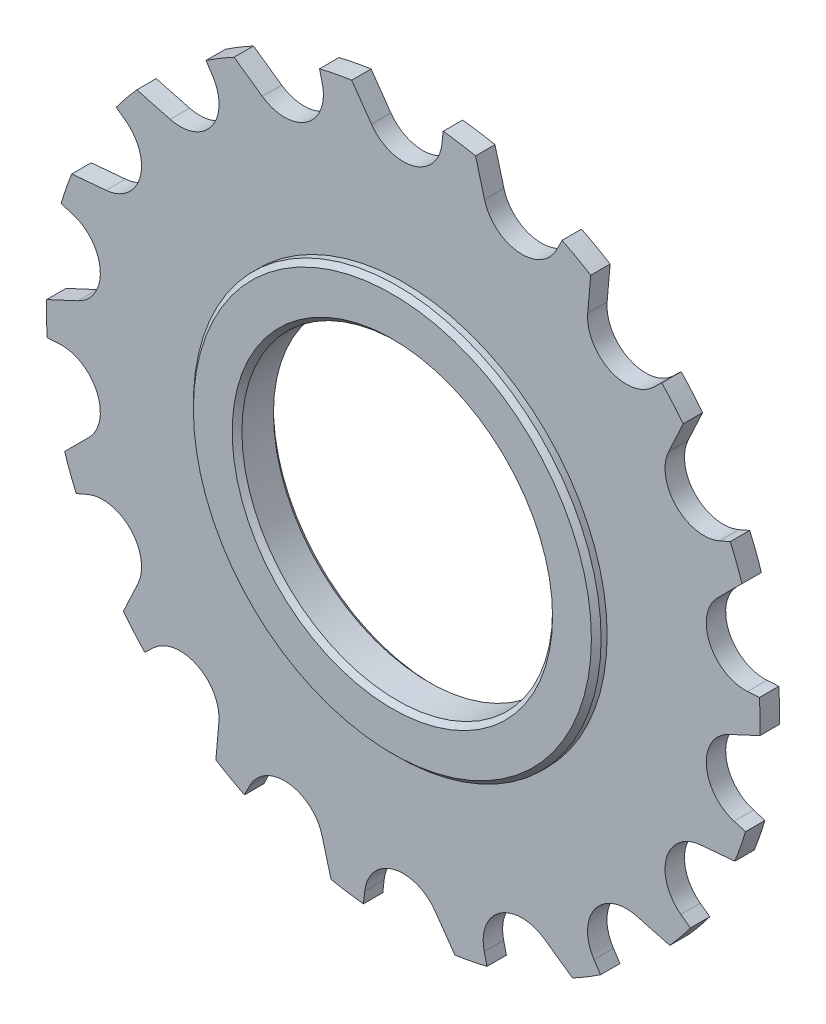
from build123d import *

# Parameters (mm, degrees)
ESQUISSE1_R                  = 36.75
EXTRUSION1_DEPTH             = 1
ENL_V_MAT_EXTRU_1_DEPTH      = 2
R_P_TITION_CIRCULAIRE1_COUNT = 18
ESQUISSE3_R                  = 21
EXTRUSION2_DEPTH             = 2.125
ESQUISSE4_R                  = 16
ENL_V_MAT_EXTRU_2_DEPTH      = 3.125
ENL_V_MAT_EXTRU_2_DEPTH_BACK = 3.125
CHANFREIN1_SIZE              = 0.5


with BuildPart() as part:
    # Esquisse1 → Extrusion1 (new body, symmetric)
    with BuildSketch(Plane.XY):
        Circle(ESQUISSE1_R)
    extrude(amount=EXTRUSION1_DEPTH, both=True)

    # Esquisse2 → Enlèv. mat.-Extru.1 (cut, symmetric)
    with BuildSketch(Plane.XY):
        with BuildLine():
            Line((-5.312971291, 36.363922177), (-3.276608177, 33.455694255))
            ThreePointArc((-3.276608177, 33.455694255), (0.987178532, 31.873728783), (3.974883244, 35.302447552))
            Line((3.974883244, 35.302447552), (4.111888112, 36.519239808))
            ThreePointArc((4.111888112, 36.519239808), (-0.605541982, 36.745010803), (-5.312971291, 36.363922177))
        make_face()
    enl_v_mat_extru_1 = extrude(amount=ENL_V_MAT_EXTRU_1_DEPTH, both=True, mode=Mode.SUBTRACT)

    # Répétition circulaire1: Enlèv. mat.-Extru.1 ×18 about axis
    r_p_tition_circulaire1_axis = Axis((0, 0, 0), (0, 0, 1))
    for i in range(1, R_P_TITION_CIRCULAIRE1_COUNT):
        add(enl_v_mat_extru_1.rotate(r_p_tition_circulaire1_axis, i * 360 / R_P_TITION_CIRCULAIRE1_COUNT), mode=Mode.SUBTRACT)

    # Esquisse3 → Extrusion2 (add, symmetric)
    with BuildSketch(Plane.XY):
        Circle(ESQUISSE3_R)
    extrude(amount=EXTRUSION2_DEPTH, both=True)

    # Esquisse4 → Enlèv. mat.-Extru.2 (cut, two sides)
    with BuildSketch(Plane.XY) as enl_v_mat_extru_2_sk:
        Circle(ESQUISSE4_R)
    extrude(amount=ENL_V_MAT_EXTRU_2_DEPTH, mode=Mode.SUBTRACT)
    extrude(enl_v_mat_extru_2_sk.sketch, amount=-ENL_V_MAT_EXTRU_2_DEPTH_BACK, mode=Mode.SUBTRACT)

    # Chanfrein1
    chanfrein1_edges = [part.edges().sort_by_distance(p)[0] for p in [
        (-21, 0, -2.125),
        (-21, 0, 2.125),
        (-16, 0, -2.125),
        (-16, 0, 2.125),
    ]]
    chamfer(chanfrein1_edges, length=CHANFREIN1_SIZE)


solid = part.part
